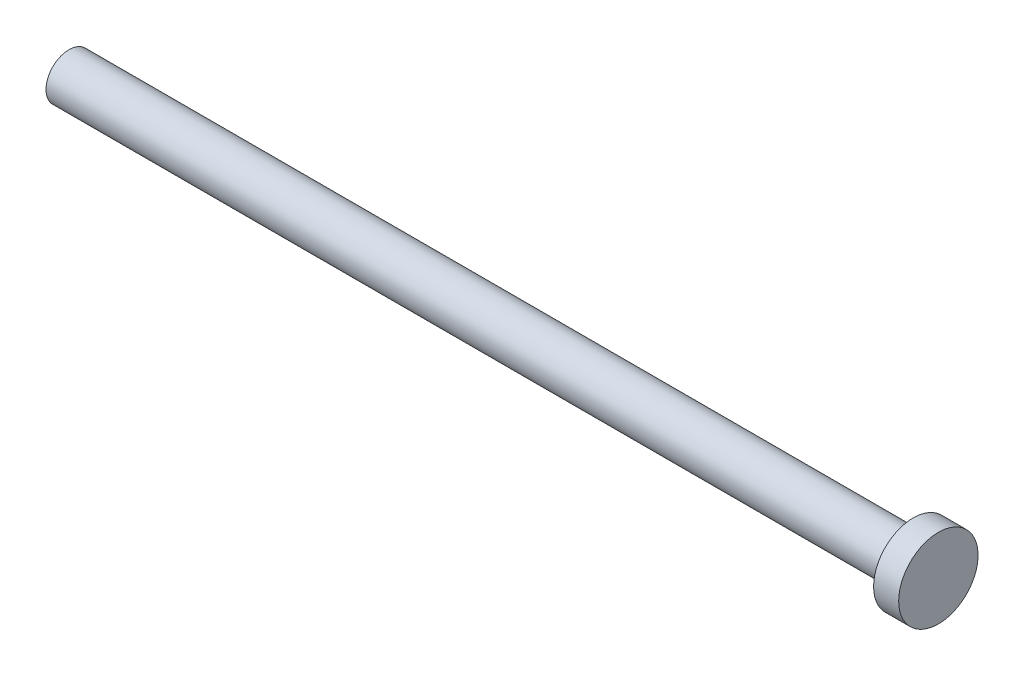
from build123d import *


with BuildPart() as part:
    # Sketch1 → Revolve1 (revolve)
    with BuildSketch(Plane.XY):
        Polygon((-26.416, 0), (26.416, 0), (26.416, 2.413), (24.892, 2.413), (24.892, 1.397), (-26.416, 1.397), align=None)
    revolve(axis=Axis((-101.547873598, 0, 0), (1, 0, 0)))


solid = part.part
